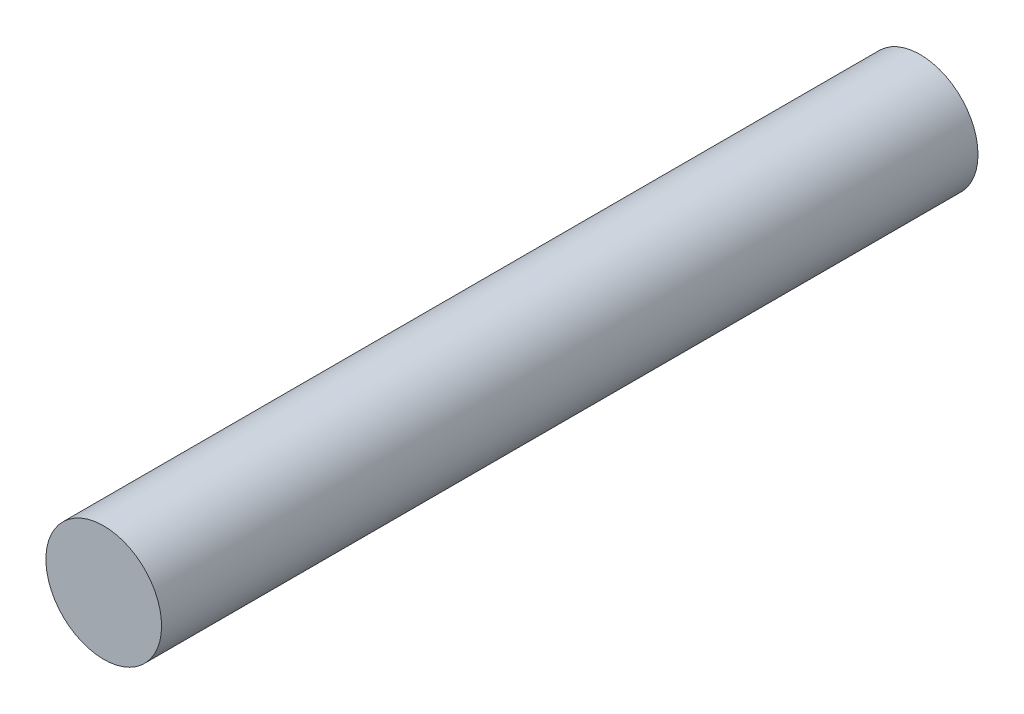
from build123d import *

# Parameters (mm, degrees)
SKETCH1_R           = 8.5
BOSS_EXTRUDE1_DEPTH = 60


with BuildPart() as part:
    # Sketch1 → Boss-Extrude1 (new body, symmetric)
    with BuildSketch(Plane.XY):
        Circle(SKETCH1_R)
    extrude(amount=BOSS_EXTRUDE1_DEPTH, both=True)


solid = part.part
